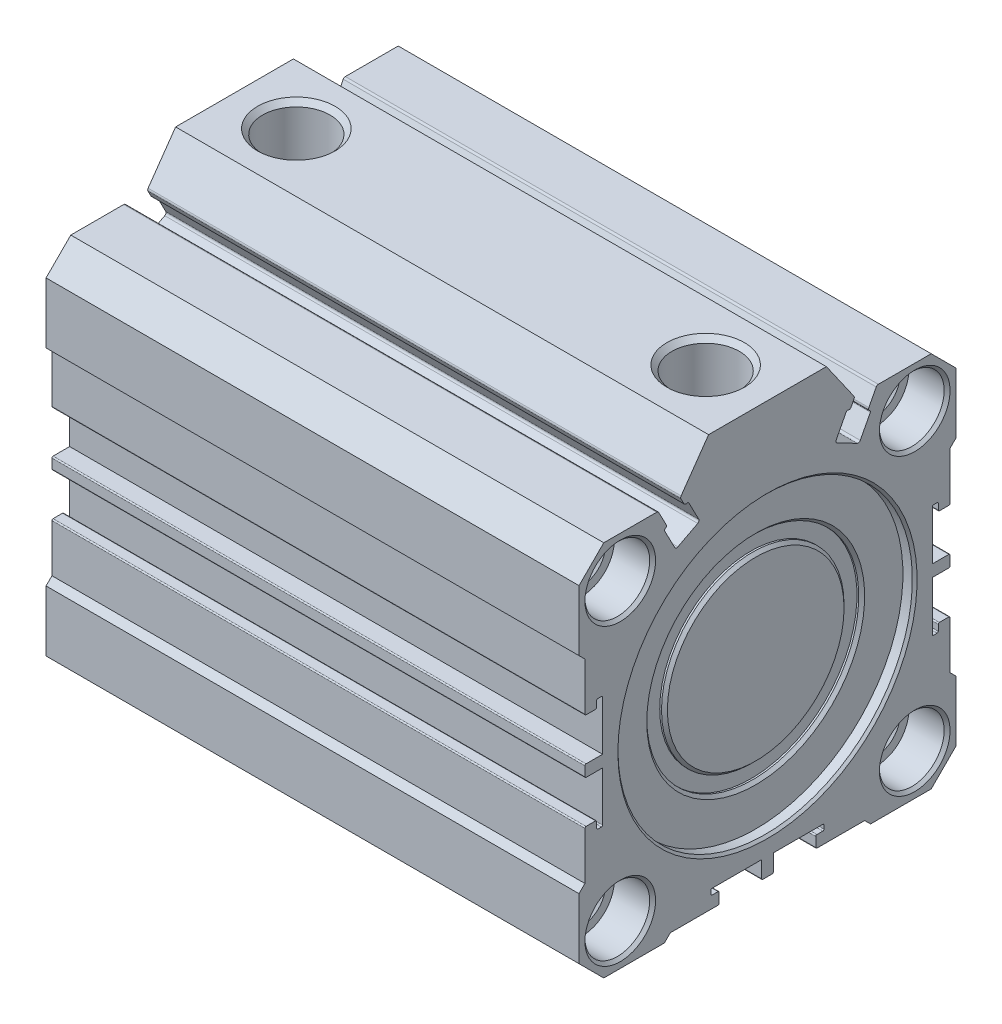
from build123d import *

# Parameters (mm, degrees)
EXTRUDE_1_DEPTH             = 90.5
PATTERN_LINEAR_1_COUNT      = 2
PATTERN_LINEAR_1_PITCH      = 50
PATTERN_LINEAR_1_COUNT_DIR2 = 2
PATTERN_LINEAR_1_PITCH_DIR2 = 50
PATTERN_LINEAR_2_COUNT      = 2
PATTERN_LINEAR_2_PITCH      = 50
PATTERN_LINEAR_2_COUNT_DIR2 = 2
PATTERN_LINEAR_2_PITCH_DIR2 = 50


with BuildPart() as part:
    # 草图1 → 凸台-拉伸1 (new body)
    with BuildSketch(Plane(origin=(0, 0, 0), x_dir=(0, 0, -1), z_dir=(1, 0, 0))):
        with BuildLine():
            Line((-32, -17.5), (-32, -27.8))
            Line((-32, -27.8), (-27.8, -32))
            Line((-27.8, -32), (-17.5, -32))
            Line((-17.5, -32), (-16.5, -31))
            Line((-16.5, -31), (-8.4, -31))
            ThreePointArc((-8.4, -31), (-8.258578644, -30.941421356), (-8.2, -30.8))
            Line((-8.2, -30.8), (-8.2, -29.2))
            ThreePointArc((-8.2, -29.2), (-8.258578644, -29.058578644), (-8.4, -29))
            Line((-8.4, -29), (-9.4, -29))
            ThreePointArc((-9.4, -29), (-9.541421356, -28.941421356), (-9.6, -28.8))
            Line((-9.6, -28.8), (-9.6, -28.2))
            ThreePointArc((-9.6, -28.2), (-9.541421356, -28.058578644), (-9.4, -28))
            Line((-9.4, -28), (-1, -28))
            Line((-1, -28), (-1, -30.8))
            ThreePointArc((-1, -30.8), (-0.941421356, -30.941421356), (-0.8, -31))
            Line((-0.8, -31), (0.8, -31))
            ThreePointArc((0.8, -31), (0.941421356, -30.941421356), (1, -30.8))
            Line((1, -30.8), (1, -28))
            Line((1, -28), (9.4, -28))
            ThreePointArc((9.4, -28), (9.541421356, -28.058578644), (9.6, -28.2))
            Line((9.6, -28.2), (9.6, -28.8))
            ThreePointArc((9.6, -28.8), (9.541421356, -28.941421356), (9.4, -29))
            Line((9.4, -29), (8.4, -29))
            ThreePointArc((8.4, -29), (8.258578644, -29.058578644), (8.2, -29.2))
            Line((8.2, -29.2), (8.2, -30.8))
            ThreePointArc((8.2, -30.8), (8.258578644, -30.941421356), (8.4, -31))
            Line((8.4, -31), (16.5, -31))
            Line((16.5, -31), (17.5, -32))
            Line((17.5, -32), (27.8, -32))
            Line((27.8, -32), (32, -27.8))
            Line((32, -27.8), (32, -17.5))
            Line((32, -17.5), (31, -16.5))
            Line((31, -16.5), (31, -8.4))
            ThreePointArc((31, -8.4), (30.941421356, -8.258578644), (30.8, -8.2))
            Line((30.8, -8.2), (29.2, -8.2))
            ThreePointArc((29.2, -8.2), (29.058578644, -8.258578644), (29, -8.4))
            Line((29, -8.4), (29, -9.4))
            ThreePointArc((29, -9.4), (28.941421356, -9.541421356), (28.8, -9.6))
            Line((28.8, -9.6), (28.2, -9.6))
            ThreePointArc((28.2, -9.6), (28.058578644, -9.541421356), (28, -9.4))
            Line((28, -9.4), (28, -1))
            Line((28, -1), (30.8, -1))
            ThreePointArc((30.8, -1), (30.941421356, -0.941421356), (31, -0.8))
            Line((31, -0.8), (31, 0.8))
            ThreePointArc((31, 0.8), (30.941421356, 0.941421356), (30.8, 1))
            Line((30.8, 1), (28, 1))
            Line((28, 1), (28, 9.4))
            ThreePointArc((28, 9.4), (28.058578644, 9.541421356), (28.2, 9.6))
            Line((28.2, 9.6), (28.8, 9.6))
            ThreePointArc((28.8, 9.6), (28.941421356, 9.541421356), (29, 9.4))
            Line((29, 9.4), (29, 8.4))
            ThreePointArc((29, 8.4), (29.058578644, 8.258578644), (29.2, 8.2))
            Line((29.2, 8.2), (30.8, 8.2))
            ThreePointArc((30.8, 8.2), (30.941421356, 8.258578644), (31, 8.4))
            Line((31, 8.4), (31, 16.5))
            Line((31, 16.5), (32, 17.5))
            Line((32, 17.5), (32, 27.8))
            Line((32, 27.8), (27.8, 32))
            Line((27.8, 32), (18.817420886, 32))
            ThreePointArc((18.817420886, 32), (18.609911583, 31.941964748), (18.462616553, 31.784699445))
            Line((18.462616553, 31.784699445), (17.207371266, 29.373395686))
            ThreePointArc((17.207371266, 29.373395686), (17.180688819, 29.06841392), (17.377476154, 28.833891907))
            ThreePointArc((17.377476154, 28.833891907), (17.475869822, 28.7166309), (17.462528598, 28.564140018))
            Line((17.462528598, 28.564140018), (15.754058729, 25.282199935))
            ThreePointArc((15.754058729, 25.282199935), (15.519536716, 25.0854126), (15.214554951, 25.112095047))
            Line((15.214554951, 25.112095047), (11.843913785, 26.866739777))
            ThreePointArc((11.843913785, 26.866739777), (11.64712645, 27.101261791), (11.673808897, 27.406243556))
            Line((11.673808897, 27.406243556), (13.382278766, 30.688183639))
            ThreePointArc((13.382278766, 30.688183639), (13.499539782, 30.786577309), (13.652030672, 30.773236074))
            ThreePointArc((13.652030672, 30.773236074), (13.957012429, 30.746553638), (14.191534434, 30.943340971))
            Line((14.191534434, 30.943340971), (14.697684494, 31.915646191))
            ThreePointArc((14.697684494, 31.915646191), (14.74202373, 32.126506888), (14.670540979, 32.329776211))
            Line((14.670540979, 32.329776211), (10, 39))
            Line((10, 39), (-10, 39))
            Line((-10, 39), (-14.670540979, 32.329776211))
            ThreePointArc((-14.670540979, 32.329776211), (-14.74202373, 32.126506888), (-14.697684494, 31.915646191))
            Line((-14.697684494, 31.915646191), (-14.191534434, 30.943340971))
            ThreePointArc((-14.191534434, 30.943340971), (-13.95701242, 30.746553636), (-13.652030655, 30.773236083))
            ThreePointArc((-13.652030655, 30.773236083), (-13.499539772, 30.786577306), (-13.382278766, 30.688183639))
            Line((-13.382278766, 30.688183639), (-11.673808897, 27.406243556))
            ThreePointArc((-11.673808897, 27.406243556), (-11.64712645, 27.101261791), (-11.843913785, 26.866739777))
            Line((-11.843913785, 26.866739777), (-15.214554951, 25.112095047))
            ThreePointArc((-15.214554951, 25.112095047), (-15.519536716, 25.0854126), (-15.754058729, 25.282199935))
            Line((-15.754058729, 25.282199935), (-17.462528598, 28.564140018))
            ThreePointArc((-17.462528598, 28.564140018), (-17.475869822, 28.7166309), (-17.377476154, 28.833891907))
            ThreePointArc((-17.377476154, 28.833891907), (-17.180688819, 29.06841392), (-17.207371266, 29.373395686))
            Line((-17.207371266, 29.373395686), (-18.462616553, 31.784699445))
            ThreePointArc((-18.462616553, 31.784699445), (-18.609911583, 31.941964748), (-18.817420886, 32))
            Line((-18.817420886, 32), (-27.8, 32))
            Line((-27.8, 32), (-32, 27.8))
            Line((-32, 27.8), (-32, 17.5))
            Line((-32, 17.5), (-31, 16.5))
            Line((-31, 16.5), (-31, 8.4))
            ThreePointArc((-31, 8.4), (-30.941421356, 8.258578644), (-30.8, 8.2))
            Line((-30.8, 8.2), (-29.2, 8.2))
            ThreePointArc((-29.2, 8.2), (-29.058578644, 8.258578644), (-29, 8.4))
            Line((-29, 8.4), (-29, 9.4))
            ThreePointArc((-29, 9.4), (-28.941421356, 9.541421356), (-28.8, 9.6))
            Line((-28.8, 9.6), (-28.2, 9.6))
            ThreePointArc((-28.2, 9.6), (-28.058578644, 9.541421356), (-28, 9.4))
            Line((-28, 9.4), (-28, 1))
            Line((-28, 1), (-30.8, 1))
            ThreePointArc((-30.8, 1), (-30.941421356, 0.941421356), (-31, 0.8))
            Line((-31, 0.8), (-31, -0.8))
            ThreePointArc((-31, -0.8), (-30.941421356, -0.941421356), (-30.8, -1))
            Line((-30.8, -1), (-28, -1))
            Line((-28, -1), (-28, -9.4))
            ThreePointArc((-28, -9.4), (-28.058578644, -9.541421356), (-28.2, -9.6))
            Line((-28.2, -9.6), (-28.8, -9.6))
            ThreePointArc((-28.8, -9.6), (-28.941421356, -9.541421356), (-29, -9.4))
            Line((-29, -9.4), (-29, -8.4))
            ThreePointArc((-29, -8.4), (-29.058578644, -8.258578644), (-29.2, -8.2))
            Line((-29.2, -8.2), (-30.8, -8.2))
            ThreePointArc((-30.8, -8.2), (-30.941421356, -8.258578644), (-31, -8.4))
            Line((-31, -8.4), (-31, -16.5))
            Line((-31, -16.5), (-32, -17.5))
        make_face()
    extrude(amount=EXTRUDE_1_DEPTH)

    # 草图2 → 切除-旋转1 (revolve, cut)
    with BuildSketch(Plane.XY.offset(25)):
        Polygon((0, -25), (0, -19.25), (0.5, -19.75), (6.5, -19.75), (6.5, -21), (7.1765, -21.6765), (45.25, -21.6765), (45.25, -25), align=None)
    cut_revolve_1 = revolve(axis=Axis((45.25, -25, 25), (-1, 0, 0)), mode=Mode.SUBTRACT)

    # 阵列(线性)1: Cut-Revolve 1 2 × 2
    with Locations(*[(0, j * PATTERN_LINEAR_1_PITCH_DIR2, -i * PATTERN_LINEAR_1_PITCH) for i in range(PATTERN_LINEAR_1_COUNT) for j in range(PATTERN_LINEAR_1_COUNT_DIR2) if (i, j) != (0, 0)]):
        add(cut_revolve_1, mode=Mode.SUBTRACT)

    # 草图4 → 切除-旋转2 (revolve, cut)
    with BuildSketch(Plane.XY.offset(25)):
        Polygon((45.25, -25), (45.25, -21.6765), (83.3235, -21.6765), (84, -21), (84, -19.5), (90, -19.5), (90.5, -19), (90.5, -25), align=None)
    cut_revolve_2 = revolve(axis=Axis((90.5, -25, 25), (-1, 0, 0)), mode=Mode.SUBTRACT)

    # 阵列(线性)2: Cut-Revolve 2 2 × 2
    with Locations(*[(0, j * PATTERN_LINEAR_2_PITCH_DIR2, -i * PATTERN_LINEAR_2_PITCH) for i in range(PATTERN_LINEAR_2_COUNT) for j in range(PATTERN_LINEAR_2_COUNT_DIR2) if (i, j) != (0, 0)]):
        add(cut_revolve_2, mode=Mode.SUBTRACT)

    # 草图6 → 切除-旋转3 (revolve, cut)
    with BuildSketch(Plane.XY):
        Polygon((0, 0), (0, 10), (10.5, 10), (10.5, 25), (83, 25), (83, 0), align=None)
    revolve(axis=Axis((83, 0, 0), (-1, 0, 0)), mode=Mode.SUBTRACT)

    # 草图7 → 切除-旋转4 (revolve, cut)
    with BuildSketch(Plane.XY):
        Polygon((0, 0), (0, 25.4), (0.4, 25), (4, 25), (4, 0), align=None)
    revolve(axis=Axis((4, 0, 0), (-1, 0, 0)), mode=Mode.SUBTRACT)

    # 草图8 → 切除-旋转5 (revolve, cut)
    with BuildSketch(Plane.XY):
        Polygon((10.5, 39), (17.0785, 39), (16.2225, 38.144), (16.2225, 29), (10.5, 29), align=None)
    revolve(axis=Axis((10.5, 29, 0), (0, 1, 0)), mode=Mode.SUBTRACT)

    # 草图9 → 切除-旋转6 (revolve, cut)
    with BuildSketch(Plane.XY):
        Polygon((80, 39), (86.5785, 39), (85.7225, 38.144), (85.7225, 29), (80, 29), align=None)
    revolve(axis=Axis((80, 29, 0), (0, 1, 0)), mode=Mode.SUBTRACT)

    # 草图10 → 旋转1 (revolve)
    with BuildSketch(Plane.XY):
        with BuildLine():
            Line((0.5, 17), (0.5, 10))
            Line((0.5, 10), (4, 10))
            Line((4, 10), (4, 17.5))
            Line((4, 17.5), (1, 17.5))
            ThreePointArc((1, 17.5), (0.646446609, 17.353553391), (0.5, 17))
        make_face()
    revolve(axis=Axis((4, 0, 0), (-1, 0, 0)))

    # 草图11 → 切除-旋转7 (revolve, cut)
    with BuildSketch(Plane.XY):
        Polygon((88.5, 0), (88.5, 25), (90.1, 25), (90.5, 25.4), (90.5, 0), align=None)
    revolve(axis=Axis((90.5, 0, 0), (-1, 0, 0)), mode=Mode.SUBTRACT)

    # 草图12 → 切除-旋转8 (revolve, cut)
    with BuildSketch(Plane.XY):
        Polygon((87.7, 15.5), (88, 15.5), (88.5, 15), (88.5, 18.5), (88, 18), (87.7, 18), align=None)
    revolve(axis=Axis((50, 0, 0), (-1, 0, 0)), mode=Mode.SUBTRACT)


solid = part.part
